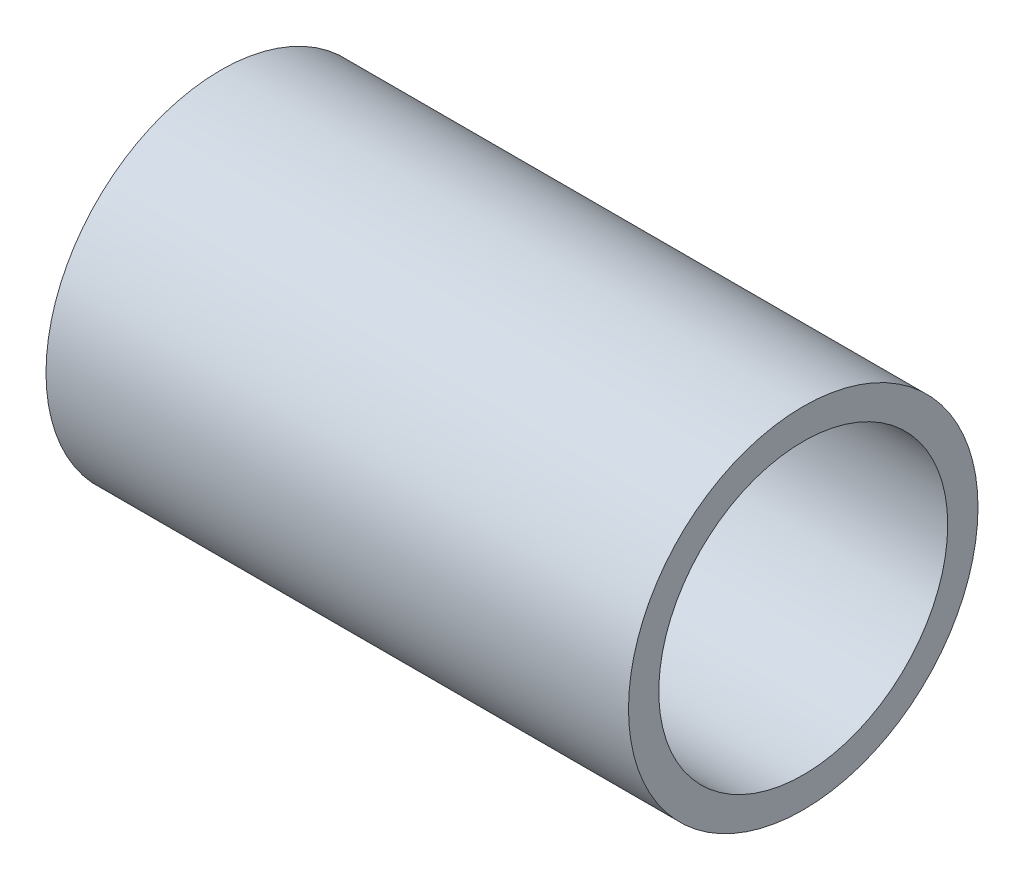
from build123d import *

# Parameters (mm, degrees)
SKETCH1_R           = 9.525
SKETCH1_R_2         = 7.874
BOSS_EXTRUDE1_DEPTH = 15.875


with BuildPart() as part:
    # Sketch1 → Boss-Extrude1 (new body, symmetric)
    with BuildSketch(Plane(origin=(0, 0, 0), x_dir=(0, 0, -1), z_dir=(1, 0, 0))):
        Circle(SKETCH1_R)
        Circle(SKETCH1_R_2, mode=Mode.SUBTRACT)
    extrude(amount=BOSS_EXTRUDE1_DEPTH, both=True)


solid = part.part
